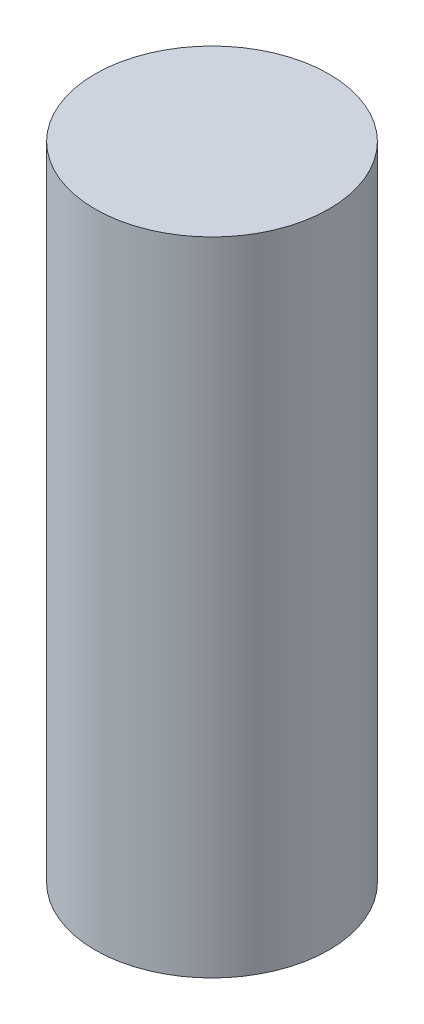
from build123d import *

# Parameters (mm, degrees)
SKETCH1_R           = 69.723
BOSS_EXTRUDE1_DEPTH = 382.524


with BuildPart() as part:
    # Sketch1 → Boss-Extrude1 (new body)
    with BuildSketch(Plane(origin=(0, 0, 0), x_dir=(1, 0, 0), z_dir=(0, 1, 0))):
        Circle(SKETCH1_R)
    extrude(amount=BOSS_EXTRUDE1_DEPTH)


solid = part.part
